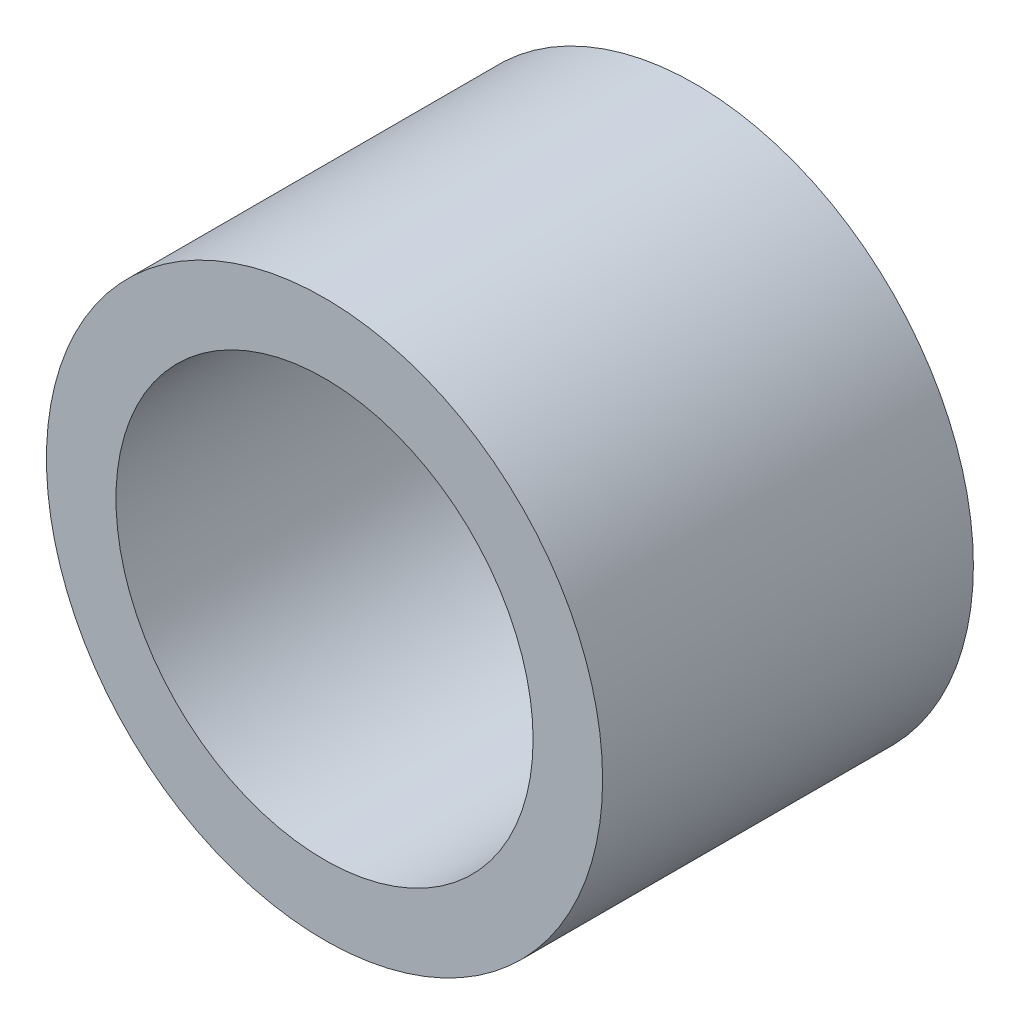
from build123d import *

# Parameters (mm, degrees)
ESQUISSE1_R        = 6
ESQUISSE1_R_2      = 4.5
BOSS_EXTRU_1_DEPTH = 4


with BuildPart() as part:
    # Esquisse1 → Boss.-Extru.1 (new body, symmetric)
    with BuildSketch(Plane.XY):
        Circle(ESQUISSE1_R)
        Circle(ESQUISSE1_R_2, mode=Mode.SUBTRACT)
    extrude(amount=BOSS_EXTRU_1_DEPTH, both=True)


solid = part.part
